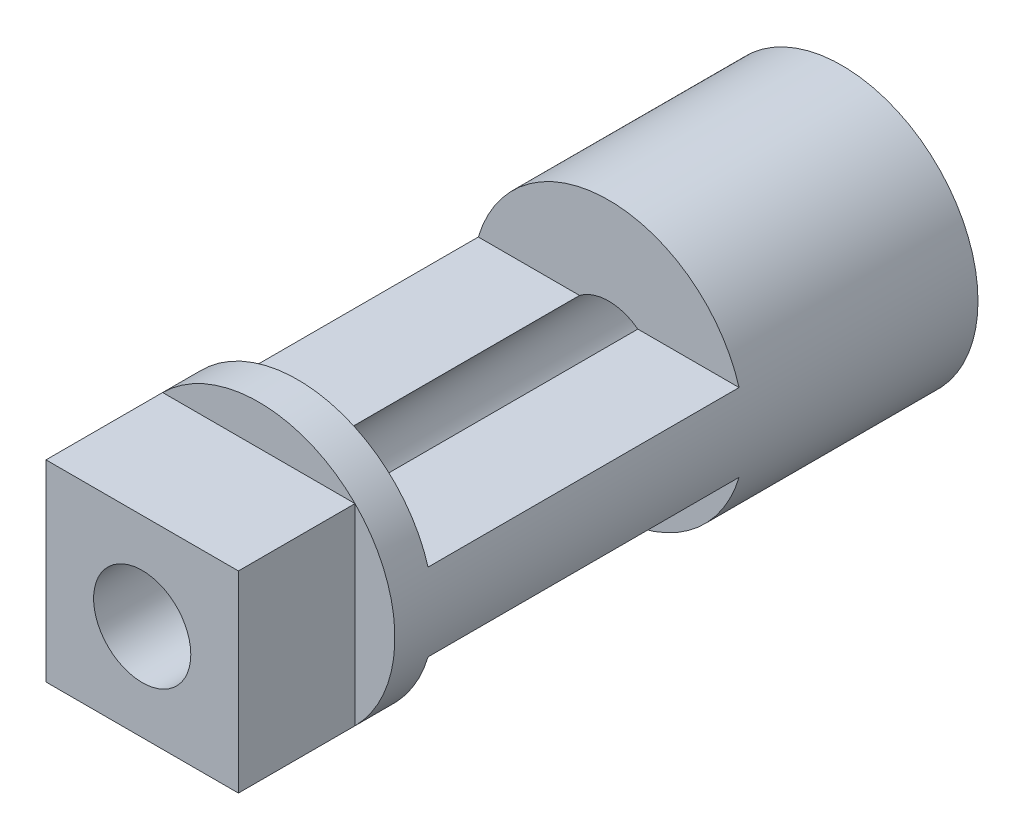
from build123d import *

# Parameters (mm, degrees)
BOSS_EXTRUDE1_START = 5
SKETCH3_R           = 3.5
SKETCH3_R_2         = 1.25
BOSS_EXTRUDE1_DEPTH = 18
SKETCH4_W           = 8
SKETCH4_H           = 2.5
CUT_EXTRUDE1_DEPTH  = 4.5
SKETCH5_OUTSIDE_W   = 13.108
SKETCH5_OUTSIDE_H   = 13.108
SKETCH5_OUTSIDE_W_2 = 4.949747468
SKETCH5_OUTSIDE_H_2 = 4.949747468
CUT_EXTRUDE2_DEPTH  = 3


with BuildPart() as part:
    # Sketch3 → Boss-Extrude1 (new body)
    with BuildSketch(Plane.XY.offset(BOSS_EXTRUDE1_START)):
        Circle(SKETCH3_R)
        Circle(SKETCH3_R_2, mode=Mode.SUBTRACT)
    extrude(amount=BOSS_EXTRUDE1_DEPTH)

    # Sketch4 → Cut-Extrude1 (cut, symmetric)
    with BuildSketch(Plane(origin=(0, 0, 0), x_dir=(0, 0, -1), z_dir=(1, 0, 0))):
        with Locations((-15, 2.25)):
            Rectangle(SKETCH4_W, SKETCH4_H)
    cut_extrude1 = extrude(amount=CUT_EXTRUDE1_DEPTH, both=True, mode=Mode.SUBTRACT)

    # Mirror1: Cut-Extrude1 across plane
    add(cut_extrude1.mirror(Plane.ZX), mode=Mode.SUBTRACT)

    # Sketch5 outside → Cut-Extrude2 (cut)
    with BuildSketch(Plane.XY.offset(23)):
        Rectangle(SKETCH5_OUTSIDE_W, SKETCH5_OUTSIDE_H)
        Rectangle(SKETCH5_OUTSIDE_W_2, SKETCH5_OUTSIDE_H_2, mode=Mode.SUBTRACT)
    extrude(amount=-CUT_EXTRUDE2_DEPTH, mode=Mode.SUBTRACT)


solid = part.part
